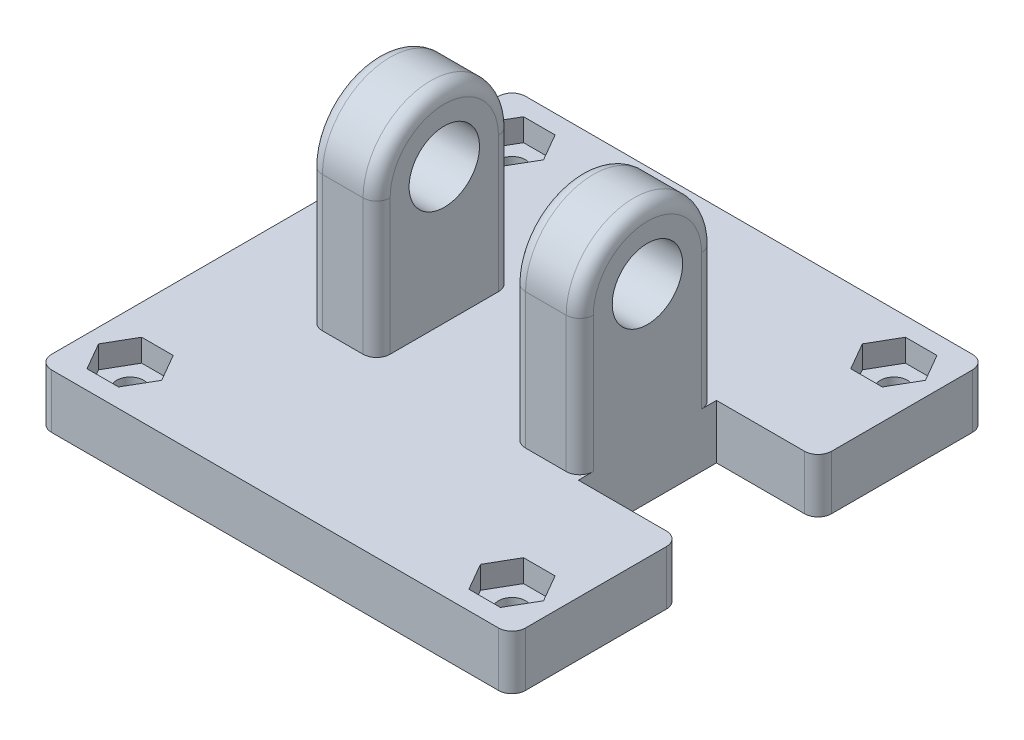
from build123d import *

# Parameters (mm, degrees)
ESQUISSE2_R             = 2.6
BOSS_EXTRU_1_DEPTH      = 10
ESQUISSE4_W             = 35
ESQUISSE4_H             = 35
BOSS_EXTRU_2_DEPTH      = 4
ENL_V_MAT_EXTRU_1_REACH = 6
ESQUISSE5_R             = 1
ESQUISSE6_W             = 10
ESQUISSE6_H             = 16.186441142
ENL_V_MAT_EXTRU_2_DEPTH = 23.5
ENL_V_MAT_EXTRU_3_DEPTH = 1.66
ENL_V_MAT_EXTRU_4_REACH = 6
ESQUISSE8_W             = 7.5
ESQUISSE8_H             = 10.2
CONG_1_R                = 1


with BuildPart() as part:
    # Esquisse2 → Boss.-Extru.1 (new body, symmetric)
    with BuildSketch(Plane(origin=(0, 0, 0), x_dir=(0, 0, -1), z_dir=(1, 0, 0))):
        with BuildLine():
            Line((5, 0), (5, -10))
            Line((5, -10), (-5, -10))
            Line((-5, -10), (-5, 0))
            ThreePointArc((-5, 0), (0, 5), (5, 0))
        make_face()
        Circle(ESQUISSE2_R, mode=Mode.SUBTRACT)
    extrude(amount=BOSS_EXTRU_1_DEPTH, both=True)

    # Esquisse4 → Boss.-Extru.2 (add)
    with BuildSketch(Plane.XZ.offset(10)):
        Rectangle(ESQUISSE4_W, ESQUISSE4_H)
    extrude(amount=BOSS_EXTRU_2_DEPTH)

    # Esquisse5 → Enlèv. mat.-Extru.1 (cut, up to next)
    with BuildSketch(Plane(origin=(0, -10, 0), x_dir=(1, 0, 0), z_dir=(0, 1, 0)), mode=Mode.PRIVATE) as enl_v_mat_extru_1_sk1:
        with Locations(Location((14.1, -14.1, 0), (0, 0, 270))):  # turned: the seam where the file's is
            Circle(ESQUISSE5_R)
    enl_v_mat_extru_1_tool1 = extrude(enl_v_mat_extru_1_sk1.sketch, amount=-ENL_V_MAT_EXTRU_1_REACH, mode=Mode.PRIVATE) & part.part
    add(enl_v_mat_extru_1_tool1.solids().sort_by_distance((14.1, -10, 14.1))[0], mode=Mode.SUBTRACT)
    # Esquisse5 → Enlèv. mat.-Extru.1 (cut, up to next)
    with BuildSketch(Plane(origin=(0, -10, 0), x_dir=(1, 0, 0), z_dir=(0, 1, 0)), mode=Mode.PRIVATE) as enl_v_mat_extru_1_sk2:
        with Locations(Location((14.1, 14.1, 0), (0, 0, 270))):  # turned: the seam where the file's is
            Circle(ESQUISSE5_R)
    enl_v_mat_extru_1_tool2 = extrude(enl_v_mat_extru_1_sk2.sketch, amount=-ENL_V_MAT_EXTRU_1_REACH, mode=Mode.PRIVATE) & part.part
    add(enl_v_mat_extru_1_tool2.solids().sort_by_distance((14.1, -10, -14.1))[0], mode=Mode.SUBTRACT)
    # Esquisse5 → Enlèv. mat.-Extru.1 (cut, up to next)
    with BuildSketch(Plane(origin=(0, -10, 0), x_dir=(1, 0, 0), z_dir=(0, 1, 0)), mode=Mode.PRIVATE) as enl_v_mat_extru_1_sk3:
        with Locations(Location((-14.1, 14.1, 0), (0, 0, 270))):  # turned: the seam where the file's is
            Circle(ESQUISSE5_R)
    enl_v_mat_extru_1_tool3 = extrude(enl_v_mat_extru_1_sk3.sketch, amount=-ENL_V_MAT_EXTRU_1_REACH, mode=Mode.PRIVATE) & part.part
    add(enl_v_mat_extru_1_tool3.solids().sort_by_distance((-14.1, -10, -14.1))[0], mode=Mode.SUBTRACT)
    # Esquisse5 → Enlèv. mat.-Extru.1 (cut, up to next)
    with BuildSketch(Plane(origin=(0, -10, 0), x_dir=(1, 0, 0), z_dir=(0, 1, 0)), mode=Mode.PRIVATE) as enl_v_mat_extru_1_sk4:
        with Locations(Location((-14.1, -14.1, 0), (0, 0, 270))):  # turned: the seam where the file's is
            Circle(ESQUISSE5_R)
    enl_v_mat_extru_1_tool4 = extrude(enl_v_mat_extru_1_sk4.sketch, amount=-ENL_V_MAT_EXTRU_1_REACH, mode=Mode.PRIVATE) & part.part
    add(enl_v_mat_extru_1_tool4.solids().sort_by_distance((-14.1, -10, 14.1))[0], mode=Mode.SUBTRACT)

    # Esquisse6 → Enlèv. mat.-Extru.2 (cut, through all)
    with BuildSketch(Plane.XY.offset(5)):
        with Locations((0, -1.906779429)):
            Rectangle(ESQUISSE6_W, ESQUISSE6_H)
    extrude(amount=-ENL_V_MAT_EXTRU_2_DEPTH, mode=Mode.SUBTRACT)

    # Esquisse7 → Enlèv. mat.-Extru.3 (cut)
    with BuildSketch(Plane(origin=(0, -10, 0), x_dir=(1, 0, 0), z_dir=(0, 1, 0))):
        Polygon((-11.77, -14.1), (-12.935, -12.082160809), (-15.265, -12.082160809), (-16.43, -14.1), (-15.265, -16.117839191), (-12.935, -16.117839191), align=None)
        Polygon((16.43, -14.1), (15.265, -12.082160809), (12.935, -12.082160809), (11.77, -14.1), (12.935, -16.117839191), (15.265, -16.117839191), align=None)
        Polygon((16.43, 14.1), (15.265, 16.117839191), (12.935, 16.117839191), (11.77, 14.1), (12.935, 12.082160809), (15.265, 12.082160809), align=None)
        Polygon((-11.77, 14.1), (-12.935, 16.117839191), (-15.265, 16.117839191), (-16.43, 14.1), (-15.265, 12.082160809), (-12.935, 12.082160809), align=None)
    extrude(amount=-ENL_V_MAT_EXTRU_3_DEPTH, mode=Mode.SUBTRACT)

    # Esquisse8 → Enlèv. mat.-Extru.4 (cut, up to next)
    with BuildSketch(Plane(origin=(0, -10, 0), x_dir=(1, 0, 0), z_dir=(0, 1, 0)), mode=Mode.PRIVATE) as enl_v_mat_extru_4_sk1:
        with Locations((13.75, 0)):
            Rectangle(ESQUISSE8_W, ESQUISSE8_H)
    enl_v_mat_extru_4_tool1 = extrude(enl_v_mat_extru_4_sk1.sketch, amount=-ENL_V_MAT_EXTRU_4_REACH, mode=Mode.PRIVATE) & part.part
    add(enl_v_mat_extru_4_tool1.solids().sort_by_distance((13.75, -10, 0))[0], mode=Mode.SUBTRACT)

    # Congé1
    cong_1_edges = [part.edges().sort_by_distance(p)[0] for p in [
        (17.5, -12, -5.1),
        (17.5, -12, 5.1),
        (10, -5, -5),
        (-17.5, -12, 17.5),
        (-17.5, -12, -17.5),
        (17.5, -12, -17.5),
        (17.5, -12, 17.5),
        (10, 5, 0),
        (-10, -5, -5),
        (-5, 5, 0),
        (-5, -5, -5),
        (5, -5, -5),
        (5, 5, 0),
        (5, -5, 5),
        (-5, -5, 5),
        (-10, -5, 5),
        (-10, 5, 0),
        (10, -5, 5),
    ]]
    fillet(cong_1_edges, radius=CONG_1_R)


solid = part.part
